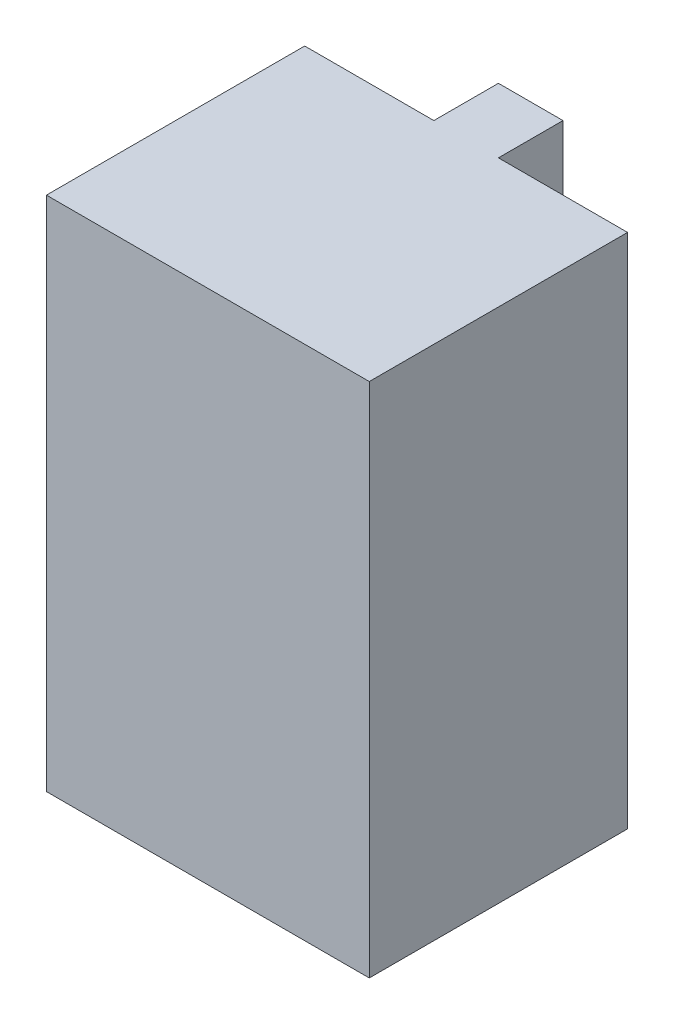
from build123d import *

# Parameters (mm, degrees)
BOSS_EXTRU_1_DEPTH = 80


with BuildPart() as part:
    # Esquisse1 → Boss.-Extru.1 (new body)
    with BuildSketch(Plane(origin=(0, 0, 0), x_dir=(1, 0, 0), z_dir=(0, 1, 0))):
        Polygon((0, 40), (20, 40), (20, 50), (30, 50), (30, 40), (50, 40), (50, 0), (0, 0), align=None)
    extrude(amount=BOSS_EXTRU_1_DEPTH)


solid = part.part
